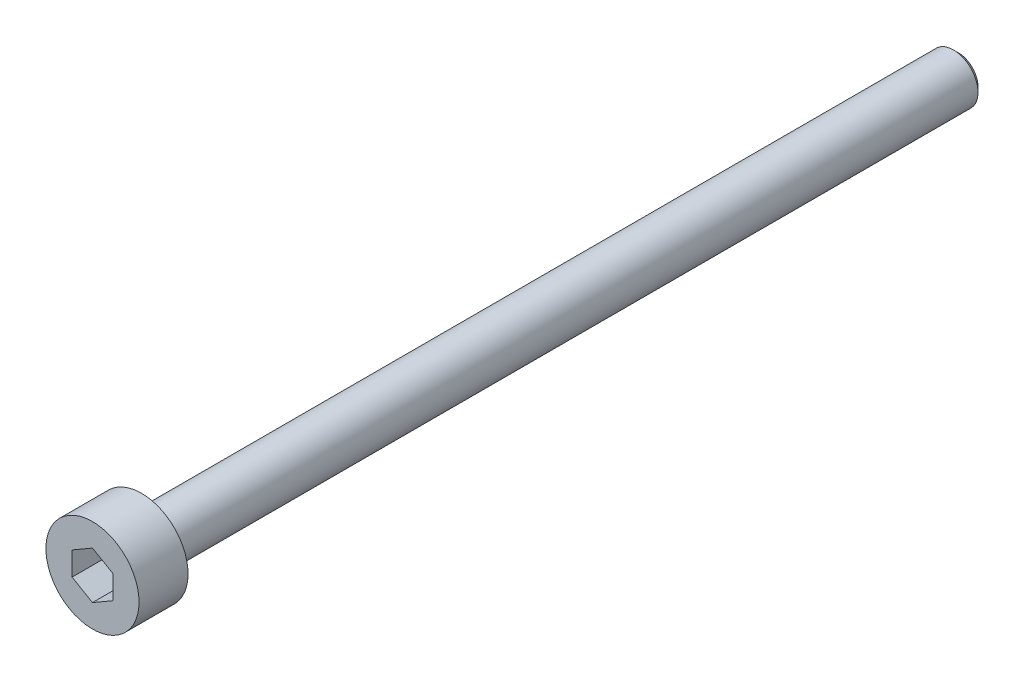
from build123d import *

# Parameters (mm, degrees)
SKETCH1_R           = 2.85
BOSS_EXTRUDE1_DEPTH = 3
SKETCH2_R           = 1.5
BOSS_EXTRUDE2_DEPTH = 50
CHAMFER1_SIZE       = 0.3
CUT_EXTRUDE1_DEPTH  = 2


with BuildPart() as part:
    # Sketch1 → Boss-Extrude1 (new body)
    with BuildSketch(Plane.XY):
        Circle(SKETCH1_R)
    extrude(amount=BOSS_EXTRUDE1_DEPTH)

    # Sketch2 → Boss-Extrude2 (add)
    with BuildSketch(Plane(origin=(0, 0, 0), x_dir=(-1, 0, 0), z_dir=(0, 0, -1))):
        Circle(SKETCH2_R)
    extrude(amount=BOSS_EXTRUDE2_DEPTH)

    # Chamfer1
    chamfer1_edges = [part.edges().sort_by_distance(p)[0] for p in [
        (1.5, 0, -50),
    ]]
    chamfer(chamfer1_edges, length=CHAMFER1_SIZE)

    # Sketch3 → Cut-Extrude1 (cut)
    with BuildSketch(Plane.XY.offset(3)):
        Polygon((0, 1.443375673), (-1.25, 0.721687836), (-1.25, -0.721687836), (0, -1.443375673), (1.25, -0.721687836), (1.25, 0.721687836), align=None)
    extrude(amount=-CUT_EXTRUDE1_DEPTH, mode=Mode.SUBTRACT)


solid = part.part
